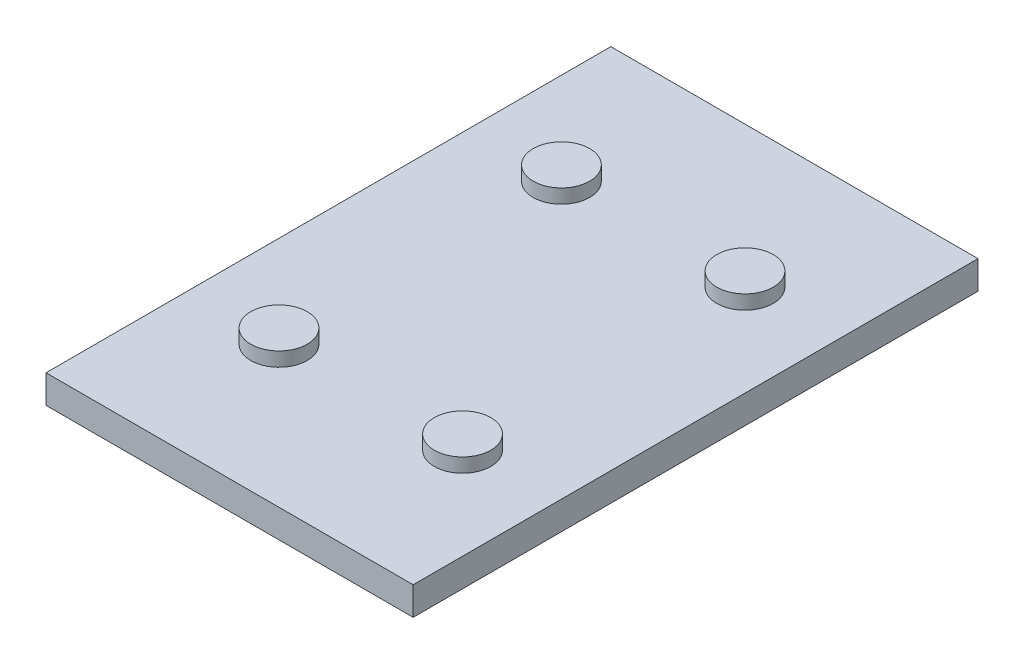
from build123d import *

# Parameters (mm, degrees)
SKETCH1_W           = 330.2
SKETCH1_H           = 508
BOSS_EXTRUDE1_DEPTH = 25.4
SKETCH2_R           = 25.4
BOSS_EXTRUDE2_DEPTH = 12.7


with BuildPart() as part:
    # Sketch1 → Boss-Extrude1 (new body)
    with BuildSketch(Plane(origin=(0, 0, 0), x_dir=(1, 0, 0), z_dir=(0, 1, 0))):
        with Locations((58.531016631, -24.295652174)):
            Rectangle(SKETCH1_W, SKETCH1_H)
    extrude(amount=BOSS_EXTRUDE1_DEPTH)

    # Sketch2 → Boss-Extrude2 (add)
    with BuildSketch(Plane(origin=(0, 25.4, 0), x_dir=(1, 0, 0), z_dir=(0, 1, 0))):
        with Locations((-24.018983369, 102.704347826)):
            Circle(SKETCH2_R)
        with Locations((141.081016631, 102.704347826)):
            Circle(SKETCH2_R)
        with Locations((141.081016631, -151.295652174)):
            Circle(SKETCH2_R)
        with Locations((-24.018983369, -151.295652174)):
            Circle(SKETCH2_R)
    extrude(amount=BOSS_EXTRUDE2_DEPTH)


solid = part.part
